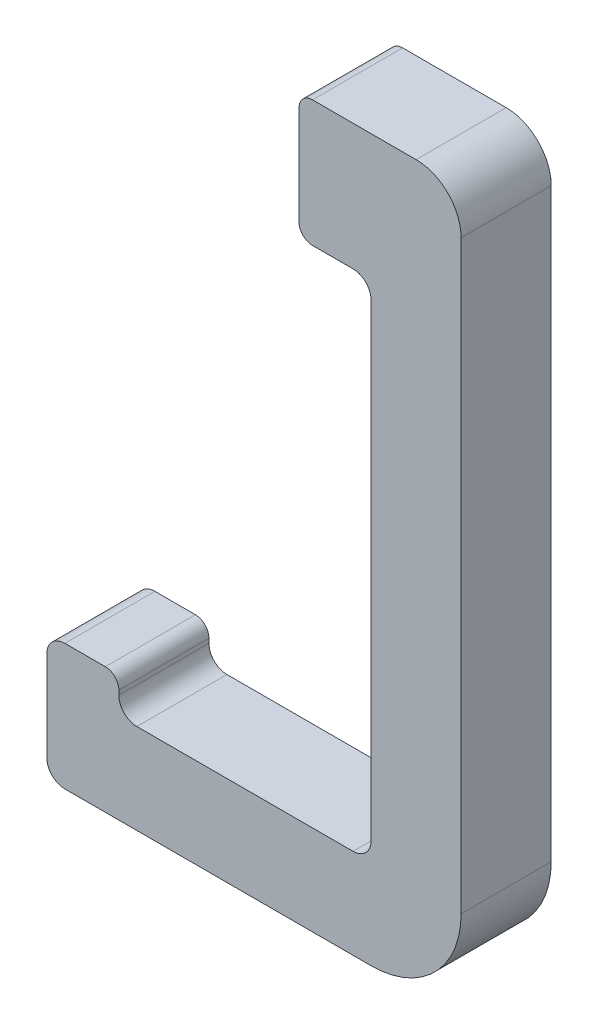
from build123d import *

# Parameters (mm, degrees)
EXTRUDE_1_DEPTH = 10


with BuildPart() as part:
    # 草图1 → 凸台-拉伸1 (new body)
    with BuildSketch(Plane.XY):
        with BuildLine():
            Line((-6.5, 66), (-2, 66))
            ThreePointArc((-2, 66), (-0.585786438, 65.414213562), (0, 64))
            Line((0, 64), (0, 16))
            Line((0, 16), (0, 12))
            ThreePointArc((0, 12), (-0.585786438, 10.585786438), (-2, 10))
            Line((-2, 10), (-6.5, 10))
            Line((-6.5, 10), (-26, 10))
            ThreePointArc((-26, 10), (-27.414213562, 10.585786438), (-28, 12))
            Line((-28, 12), (-28, 12.5))
            ThreePointArc((-28, 12.5), (-28.439339828, 13.560660172), (-29.5, 14))
            Line((-29.5, 14), (-34, 14))
            ThreePointArc((-34, 14), (-35.414213562, 13.414213562), (-36, 12))
            Line((-36, 12), (-36, 2))
            ThreePointArc((-36, 2), (-35.414213562, 0.585786438), (-34, 0))
            Line((-34, 0), (0, 0))
            ThreePointArc((0, 0), (7.071067812, 2.928932188), (10, 10))
            Line((10, 10), (10, 75))
            ThreePointArc((10, 75), (8.535533906, 78.535533906), (5, 80))
            Line((5, 80), (-6.5, 80))
            ThreePointArc((-6.5, 80), (-7.560660172, 79.560660172), (-8, 78.5))
            Line((-8, 78.5), (-8, 67.5))
            ThreePointArc((-8, 67.5), (-7.560660172, 66.439339828), (-6.5, 66))
        make_face()
    extrude(amount=EXTRUDE_1_DEPTH)


solid = part.part
